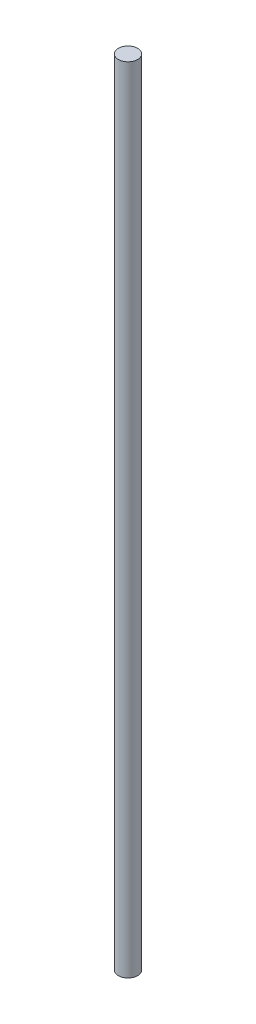
from build123d import *

# Parameters (mm, degrees)
SKETCH1_R           = 2.5
BOSS_EXTRUDE1_DEPTH = 205


with BuildPart() as part:
    # Sketch1 → Boss-Extrude1 (new body)
    with BuildSketch(Plane(origin=(0, 0, 0), x_dir=(1, 0, 0), z_dir=(0, 1, 0))):
        Circle(SKETCH1_R)
    extrude(amount=BOSS_EXTRUDE1_DEPTH)


solid = part.part
